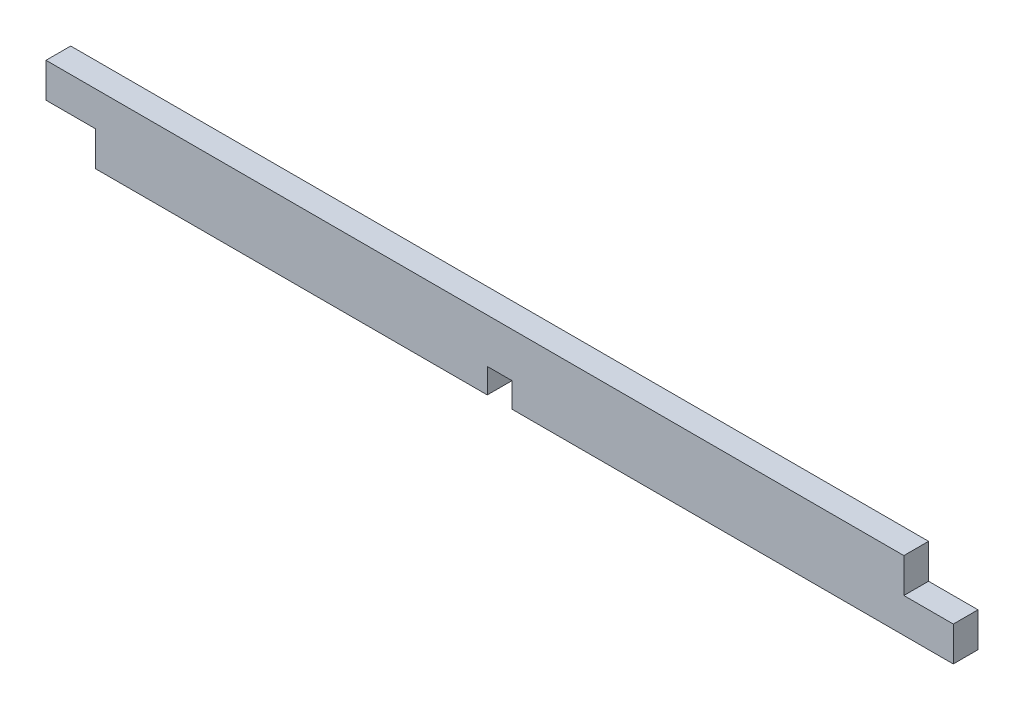
from build123d import *

# Parameters (mm, degrees)
EXTRUDE_1_DEPTH = 1.4


with BuildPart() as part:
    # Эскиз1 → Бобышка-Вытянуть1 (new, symmetric)
    with BuildSketch(Plane.XY):
        Polygon((-51.4, 0), (-45.8, 0), (-45.8, -3.92), (-1.4, -3.92), (-1.4, -1.12), (1.4, -1.12), (1.4, -3.92), (51.4, -3.92), (51.4, 0), (45.8, 0), (45.8, 3.92), (-51.4, 3.92), align=None)
    extrude(amount=EXTRUDE_1_DEPTH, both=True)


solid = part.part
